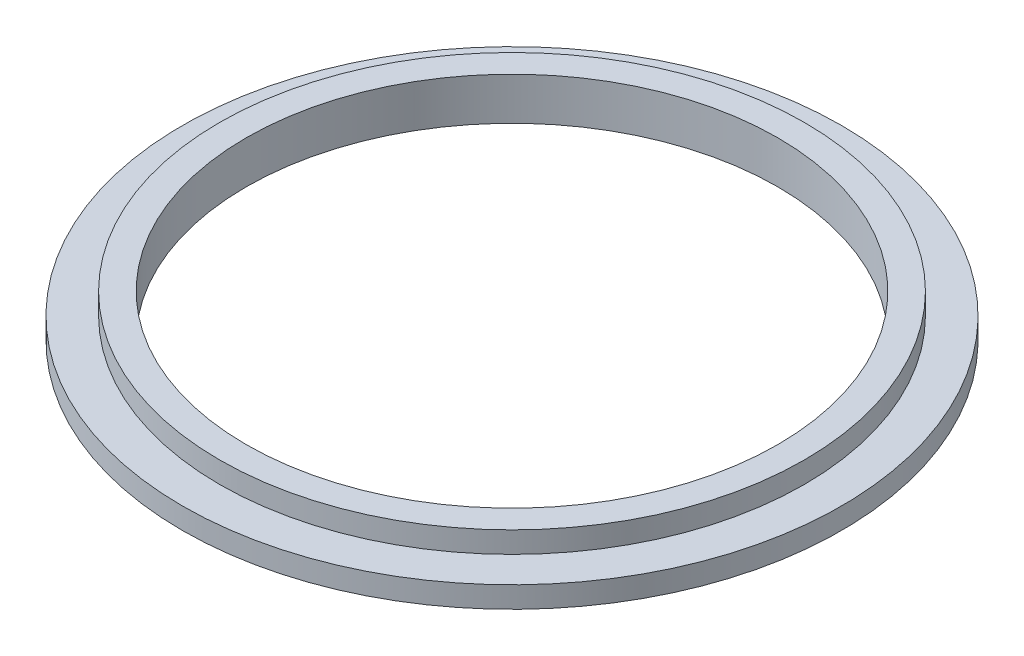
from build123d import *

# Parameters (mm, degrees)
SKETCH1_R           = 310
SKETCH1_R_2         = 250
BOSS_EXTRUDE1_DEPTH = 20
SKETCH2_R           = 275
SKETCH2_R_2         = 250
BOSS_EXTRUDE2_DEPTH = 20


with BuildPart() as part:
    # Sketch1 → Boss-Extrude1 (new body)
    with BuildSketch(Plane(origin=(0, 0, 0), x_dir=(1, 0, 0), z_dir=(0, 1, 0))):
        Circle(SKETCH1_R)
        Circle(SKETCH1_R_2, mode=Mode.SUBTRACT)
    extrude(amount=BOSS_EXTRUDE1_DEPTH)

    # Sketch2 → Boss-Extrude2 (add)
    with BuildSketch(Plane(origin=(0, 20, 0), x_dir=(1, 0, 0), z_dir=(0, 1, 0))):
        Circle(SKETCH2_R)
        Circle(SKETCH2_R_2, mode=Mode.SUBTRACT)
    extrude(amount=BOSS_EXTRUDE2_DEPTH)


solid = part.part
